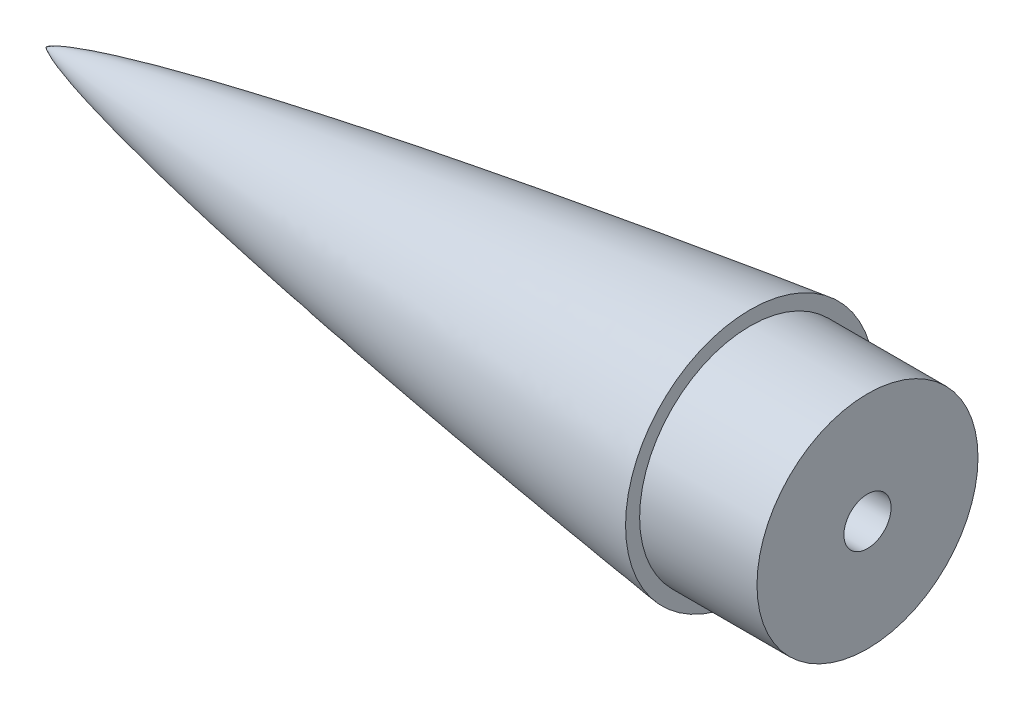
from build123d import *

# Parameters (mm, degrees)
SKETCH5_R                   = 11.960253633
BOSS_EXTRUDE1_DEPTH         = 12.7
F_1_4_20_TAPPED_HOLE2_D     = 5.1054
F_1_4_20_TAPPED_HOLE2_DEPTH = 49.266183098
F_1_4_20_TAPPED_HOLE2_TIP   = 1.533816902


with BuildPart() as part:
    # Sketch1 → Revolve1 (revolve)
    with BuildSketch(Plane.XY):
        with BuildLine():
            add(Edge.make_bspline(
                [(0, 0), (0.002571816, 0.005636479), (0.008650277, 0.016277868), (0.02483848, 0.034868542), (0.061438442, 0.067796346), (0.11568342, 0.108106243), (0.188045788, 0.154613181), (0.290833284, 0.214020736), (0.414160493, 0.278607766), (0.558777254, 0.348299144), (0.724730868, 0.422703949), (0.964147345, 0.524034824), (1.334653554, 0.66967944), (1.969293614, 0.897871425), (3.107012354, 1.265050336), (5.14211507, 1.847230264), (8.924556038, 2.793592314), (16.054272938, 4.333517796), (28.77450762, 6.681938646), (45.431814311, 9.311446564), (60.183738769, 11.387854186), (71.267871222, 12.850291408), (76.2, 13.484253633)],
                knots=[0, 0, 0, 0, 0, 4.0096e-05, 8.0192e-05, 0.000160384, 0.000320768, 0.000481152, 0.000641536, 0.000935615, 0.001229694, 0.001529439, 0.001829184, 0.002633407, 0.003829323, 0.005933298, 0.009635505, 0.01645519, 0.029289188, 0.0535632, 0.094103309, 0.126579539, 0.126579539, 0.126579539, 0.126579539, 0.126579539], degree=4))
            Line((0, 0), (4.243228297, 0))
            Line((4.243228297, 0), (76.2, 0))
            Line((76.2, 0), (76.2, 11.947705801))
            Line((76.2, 11.947705801), (76.2, 13.484253633))
        make_face()
    revolve(axis=Axis((0, 0, 0), (1, 0, 0)))

    # Sketch5 → Boss-Extrude1 (add)
    with BuildSketch(Plane(origin=(76.2, 0, 0), x_dir=(0, 0, -1), z_dir=(1, 0, 0))):
        Circle(SKETCH5_R)
    extrude(amount=BOSS_EXTRUDE1_DEPTH)

    # 1/4-20 Tapped Hole2
    with Locations(Plane(origin=(88.9, 0, 0), x_dir=(0, 0, -1), z_dir=(1, 0, 0))):
        with Locations((0, 0)):
            Hole(F_1_4_20_TAPPED_HOLE2_D / 2, depth=F_1_4_20_TAPPED_HOLE2_DEPTH)
            with Locations((0, 0, -(F_1_4_20_TAPPED_HOLE2_DEPTH + F_1_4_20_TAPPED_HOLE2_TIP / 2))):  # 118° drill point
                Cone(0, F_1_4_20_TAPPED_HOLE2_D / 2, F_1_4_20_TAPPED_HOLE2_TIP, mode=Mode.SUBTRACT)


solid = part.part
